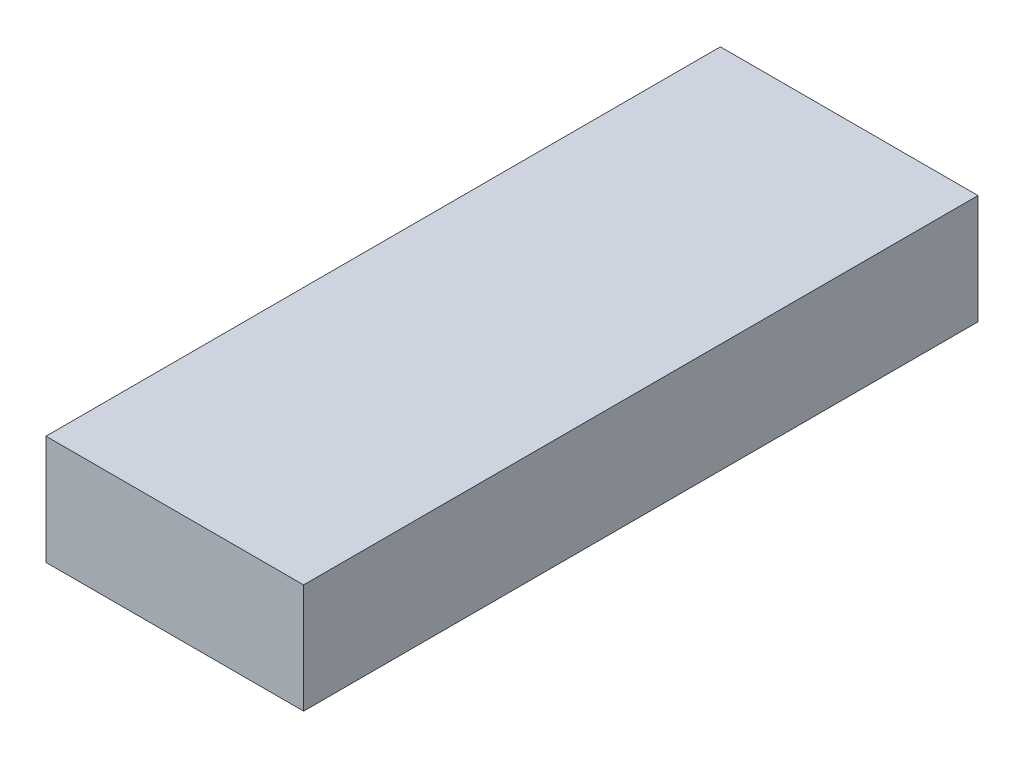
from build123d import *

# Parameters (mm, degrees)
SKETCH1_W           = 26.924
SKETCH1_H           = 70.485
BOSS_EXTRUDE1_DEPTH = 5.715


with BuildPart() as part:
    # Sketch1 → Boss-Extrude1 (new body, symmetric)
    with BuildSketch(Plane(origin=(0, 0, 0), x_dir=(1, 0, 0), z_dir=(0, 1, 0))):
        Rectangle(SKETCH1_W, SKETCH1_H)
    extrude(amount=BOSS_EXTRUDE1_DEPTH, both=True)


solid = part.part
